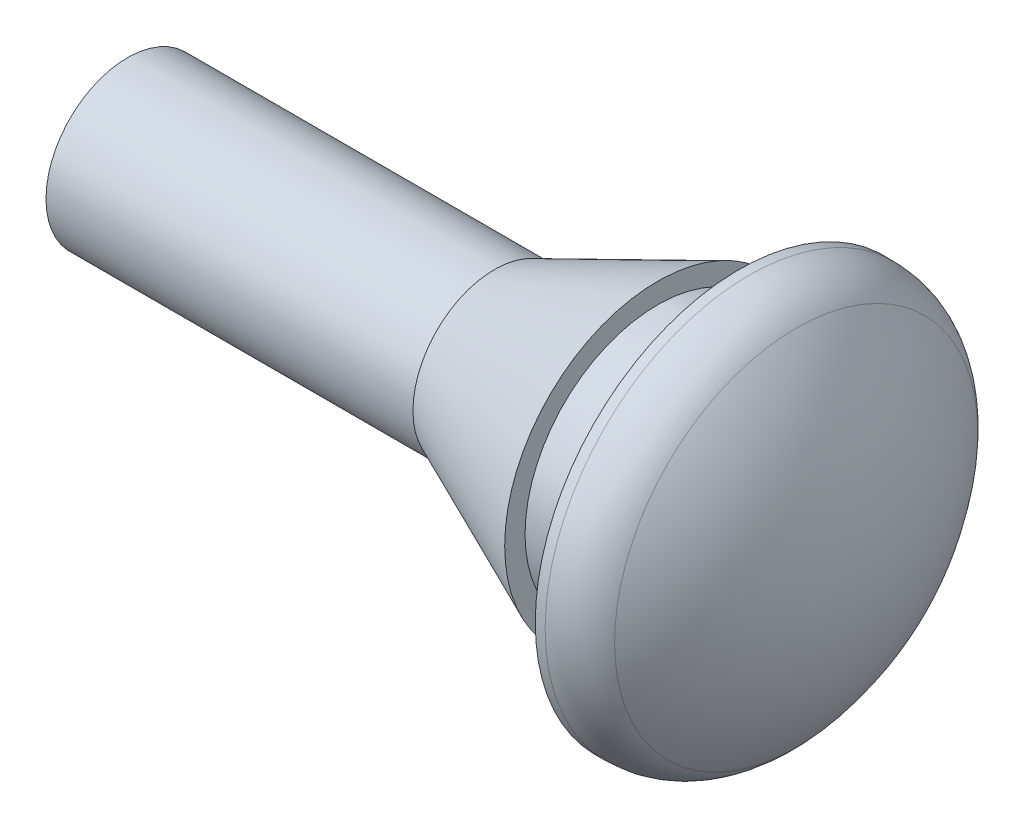
from build123d import *


with BuildPart() as part:
    # Esquisse1 → Révolution1 (revolve)
    with BuildSketch(Plane.XY, mode=Mode.PRIVATE) as r_volution1_sk:
        with BuildLine():
            Line((0, 0), (-18, 0))
            Line((-18, 0), (-18, 2))
            Line((-18, 2), (-9, 2))
            Line((-9, 2), (-5, 3.75))
            Line((-5, 3.75), (-5, 3.25))
            Line((-5, 3.25), (-3, 3.25))
            Line((-3, 3.25), (-3, 5))
            Line((-3, 5), (-2.757359313, 5))
            ThreePointArc((-2.757359313, 5), (-2.117757164, 4.856801051), (-1.600275489, 4.454545455))
            ThreePointArc((-1.600275489, 4.454545455), (-0.412205544, 2.366635631), (0, 0))
        make_face()
    revolve(r_volution1_sk.sketch.rotate(Axis((0, 0, 0), (1, 0, 0)), 90), axis=Axis((0, 0, 0), (1, 0, 0)))  # turned: the seam where the file's is


solid = part.part
